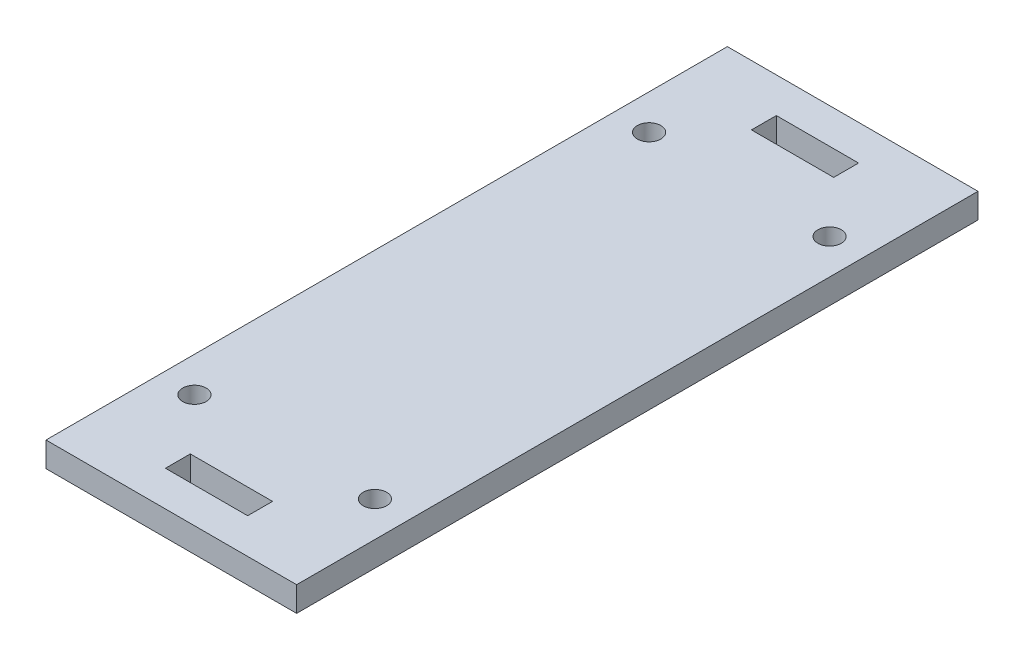
from build123d import *

# Parameters (mm, degrees)
SKETCH1_W           = 32
SKETCH1_H           = 87
SKETCH1_R           = 1.5
SKETCH1_W_2         = 10.5
SKETCH1_H_2         = 3.175
BOSS_EXTRUDE1_DEPTH = 3.175


with BuildPart() as part:
    # Sketch1 → Boss-Extrude1 (new body)
    with BuildSketch(Plane(origin=(0, 0, 0), x_dir=(1, 0, 0), z_dir=(0, 1, 0))):
        with Locations((16, 43.5)):
            Rectangle(SKETCH1_W, SKETCH1_H)
        with Locations((4.475, 72.525)):
            Circle(SKETCH1_R, mode=Mode.SUBTRACT)
        with Locations((27.525, 72.525)):
            Circle(SKETCH1_R, mode=Mode.SUBTRACT)
        with Locations((27.525, 14.475)):
            Circle(SKETCH1_R, mode=Mode.SUBTRACT)
        with Locations((4.475, 14.475)):
            Circle(SKETCH1_R, mode=Mode.SUBTRACT)
        with Locations((16, 6.0875)):
            Rectangle(SKETCH1_W_2, SKETCH1_H_2, mode=Mode.SUBTRACT)
        with Locations((16, 80.9125)):
            Rectangle(SKETCH1_W_2, SKETCH1_H_2, mode=Mode.SUBTRACT)
    extrude(amount=BOSS_EXTRUDE1_DEPTH)


solid = part.part
